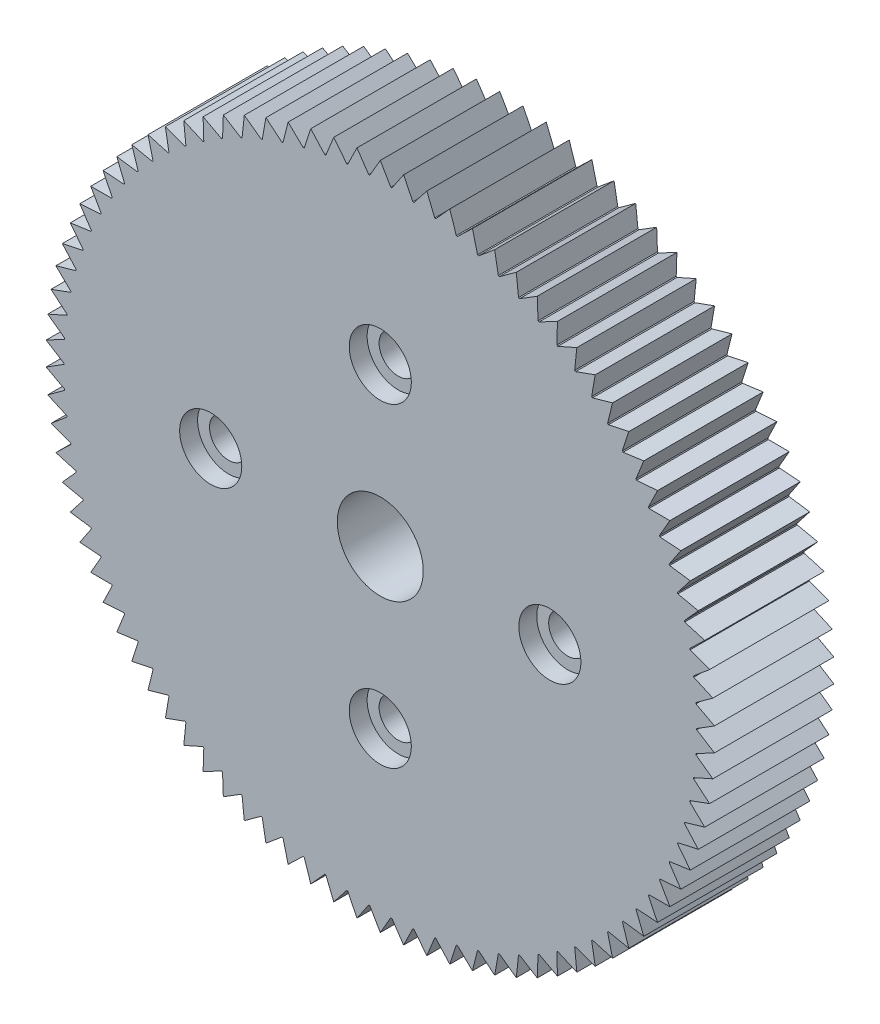
from build123d import *

# Parameters (mm, degrees)
SKETCH1_R      = 13.25
EXTRUDE1_DEPTH = 5
EXTRUDE2_DEPTH = 1.2
SKETCH3_R      = 1.8
EXTRUDE3_DEPTH = 4.8
SKETCH4_R      = 0.8
EXTRUDE4_DEPTH = 4.8
SKETCH5_R      = 1.3
EXTRUDE5_DEPTH = 0.75
EXTRUDE6_DEPTH = 5


with BuildPart() as part:
    # Sketch1 → Extrude1 (new body)
    with BuildSketch(Plane.XY):
        Circle(SKETCH1_R)
    extrude(amount=EXTRUDE1_DEPTH)

    # Sketch2 → Extrude2 (cut)
    with BuildSketch(Plane(origin=(0, 0, 0), x_dir=(-1, 0, 0), z_dir=(0, 0, -1))):
        with BuildLine():
            Line((-7.1, 1.675), (-2.36735612, 1.675))
            ThreePointArc((-2.36735612, 1.675), (-2.050609665, 2.050609665), (-1.675, 2.36735612))
            Line((-1.675, 2.36735612), (-1.675, 6.6))
            ThreePointArc((-1.675, 6.6), (0, 8.275), (1.675, 6.6))
            Line((1.675, 6.6), (1.675, 2.36735612))
            ThreePointArc((1.675, 2.36735612), (2.050609665, 2.050609665), (2.36735612, 1.675))
            Line((2.36735612, 1.675), (7.1, 1.675))
            ThreePointArc((7.1, 1.675), (8.775, 0), (7.1, -1.675))
            Line((7.1, -1.675), (2.36735612, -1.675))
            ThreePointArc((2.36735612, -1.675), (2.050609665, -2.050609665), (1.675, -2.36735612))
            Line((1.675, -2.36735612), (1.675, -6.6))
            ThreePointArc((1.675, -6.6), (0, -8.275), (-1.675, -6.6))
            Line((-1.675, -6.6), (-1.675, -2.36735612))
            ThreePointArc((-1.675, -2.36735612), (-2.050609665, -2.050609665), (-2.36735612, -1.675))
            Line((-2.36735612, -1.675), (-7.1, -1.675))
            ThreePointArc((-7.1, -1.675), (-8.775, 0), (-7.1, 1.675))
        make_face()
    extrude(amount=-EXTRUDE2_DEPTH, mode=Mode.SUBTRACT)

    # Sketch3 → Extrude3 (cut, through all)
    with BuildSketch(Plane(origin=(0, 0, 1.2), x_dir=(-1, 0, 0), z_dir=(0, 0, -1))):
        Circle(SKETCH3_R)
    extrude(amount=-EXTRUDE3_DEPTH, mode=Mode.SUBTRACT)

    # Sketch4 → Extrude4 (cut, through all)
    with BuildSketch(Plane(origin=(0, 0, 1.2), x_dir=(-1, 0, 0), z_dir=(0, 0, -1))):
        with Locations((0, 6.6)):
            Circle(SKETCH4_R)
        with Locations((-7.1, 0)):
            Circle(SKETCH4_R)
        with Locations((0, -6.6)):
            Circle(SKETCH4_R)
        with Locations((7.1, 0)):
            Circle(SKETCH4_R)
    extrude(amount=-EXTRUDE4_DEPTH, mode=Mode.SUBTRACT)

    # Sketch5 → Extrude5 (cut)
    with BuildSketch(Plane.XY.offset(5)):
        with Locations((-7.1, 0)):
            Circle(SKETCH5_R)
        with Locations((0, -6.6)):
            Circle(SKETCH5_R)
        with Locations((7.1, 0)):
            Circle(SKETCH5_R)
        with Locations((0, 6.6)):
            Circle(SKETCH5_R)
    extrude(amount=-EXTRUDE5_DEPTH, mode=Mode.SUBTRACT)

    # Sketch6 → Extrude6 (add)
    with BuildSketch(Plane(origin=(0, 0, 0), x_dir=(-1, 0, 0), z_dir=(0, 0, -1))):
        with BuildLine():
            Line((0, 14), (-0.439306114, 13.242715361))
            ThreePointArc((-0.439306114, 13.242715361), (0, 13.25), (0.439306114, 13.242715361))
            Line((0.439306114, 13.242715361), (0, 14))
        make_face()
        with BuildLine():
            Line((1.362001112, 13.179812327), (0.976590632, 13.965896704))
            Line((0.976590632, 13.965896704), (0.48552914, 13.241101218))
            ThreePointArc((0.48552914, 13.241101218), (0.924273277, 13.217723666), (1.362001112, 13.179812327))
        make_face()
        with BuildLine():
            Line((2.278060579, 13.052698572), (1.948423413, 13.863752962))
            Line((1.948423413, 13.863752962), (1.407998945, 13.17497776))
            ThreePointArc((1.407998945, 13.17497776), (1.844043588, 13.121051911), (2.278060579, 13.052698572))
        make_face()
        with BuildLine():
            Line((3.183021563, 12.861993381), (2.910763671, 13.69406641))
            Line((2.910763671, 13.69406641), (2.323609121, 13.044667135))
            ThreePointArc((2.323609121, 13.044667135), (2.754829903, 12.96045571), (3.183021563, 12.861993381))
        make_face()
        with BuildLine():
            Line((4.072475186, 12.608625851), (3.858922981, 13.457663743))
            Line((3.858922981, 13.457663743), (3.227898906, 12.850804203))
            ThreePointArc((3.227898906, 12.850804203), (3.652194965, 12.736717471), (4.072475186, 12.608625851))
        make_face()
        with BuildLine():
            Line((4.942088119, 12.293830364), (4.788282007, 13.155696691))
            Line((4.788282007, 13.155696691), (4.116462693, 12.594333444))
            ThreePointArc((4.116462693, 12.594333444), (4.531766899, 12.450927225), (4.942088119, 12.293830364))
        make_face()
        with BuildLine():
            Line((5.787623696, 11.919140571), (5.694313003, 12.789636407))
            Line((5.694313003, 12.789636407), (4.984971487, 12.276504359))
            ThreePointArc((4.984971487, 12.276504359), (5.389260521, 12.104477314), (5.787623696, 11.919140571))
        make_face()
        with BuildLine():
            Line((6.604962552, 11.486381923), (6.572601879, 12.3612663))
            Line((6.572601879, 12.3612663), (5.829194001, 11.898865379))
            ThreePointArc((5.829194001, 11.898865379), (6.220498207, 11.699055605), (6.604962552, 11.486381923))
        make_face()
        with BuildLine():
            Line((7.390122694, 10.997662778), (7.418869699, 11.872673346))
            Line((7.418869699, 11.872673346), (6.645017267, 11.463256323))
            ThreePointArc((6.645017267, 11.463256323), (7.021430251, 11.236637274), (7.390122694, 10.997662778))
        make_face()
        with BuildLine():
            Line((8.139278901, 10.455364124), (8.228993532, 11.326237921))
            Line((8.228993532, 11.326237921), (7.428466678, 10.971799434))
            ThreePointArc((7.428466678, 10.971799434), (7.788154593, 10.719475175), (8.139278901, 10.455364124))
        make_face()
        with BuildLine():
            Line((8.84878136, 9.862127988), (8.999026536, 10.724622204))
            Line((8.999026536, 10.724622204), (8.175725346, 10.426889041))
            ThreePointArc((8.175725346, 10.426889041), (8.516935828, 10.150088871), (8.84878136, 9.862127988))
        make_face()
        with BuildLine():
            Line((9.515173445, 9.220844555), (9.725217186, 10.070757205))
            Line((9.725217186, 10.070757205), (8.883152701, 9.831179893))
            ThreePointArc((8.883152701, 9.831179893), (9.204223409, 9.531252354), (9.515173445, 9.220844555))
        make_face()
        with BuildLine():
            Line((10.135208562, 8.534638094), (10.404027557, 9.367828489))
            Line((10.404027557, 9.367828489), (9.54730223, 9.187574225))
            ThreePointArc((9.54730223, 9.187574225), (9.846668938, 8.865980534), (10.135208562, 8.534638094))
        make_face()
        with BuildLine():
            Line((10.705865962, 7.806851735), (11.03215055, 8.619260655))
            Line((11.03215055, 8.619260655), (10.164938262, 8.499207618))
            ThreePointArc((10.164938262, 8.499207618), (10.441142485, 8.157514548), (10.705865962, 7.806851735))
        make_face()
        with BuildLine():
            Line((11.224365458, 7.041031179), (11.606526016, 7.828700649))
            Line((11.606526016, 7.828700649), (10.733051736, 7.769433727))
            ThreePointArc((10.733051736, 7.769433727), (10.984747836, 7.409305971), (11.224365458, 7.041031179))
        make_face()
        with BuildLine():
            Line((11.688180975, 6.240907426), (12.124355653, 7))
            Line((12.124355653, 7), (11.248874861, 7.001807935))
            ThreePointArc((11.248874861, 7.001807935), (11.4748366, 6.625), (11.688180975, 6.240907426))
        make_face()
        with BuildLine():
            Line((12.095052848, 5.4103786), (12.583116648, 6.137196055))
            Line((12.583116648, 6.137196055), (11.709894599, 6.200070039))
            ThreePointArc((11.709894599, 6.200070039), (11.909021113, 5.808417695), (12.095052848, 5.4103786))
        make_face()
        with BuildLine():
            Line((12.44299884, 4.553490953), (12.980573964, 5.244492308))
            Line((12.980573964, 5.244492308), (12.113864907, 5.368126025))
            ThreePointArc((12.113864907, 5.368126025), (12.285186073, 4.963537363), (12.44299884, 4.553490953))
        make_face()
        with BuildLine():
            Line((12.730323793, 3.674419156), (13.314791228, 4.326237921))
            Line((13.314791228, 4.326237921), (12.458817683, 4.51002904))
            ThreePointArc((12.458817683, 4.51002904), (12.601498841, 4.094475175), (12.730323793, 3.674419156))
        make_face()
        with BuildLine():
            Line((12.955627887, 2.777445958), (13.584140168, 3.386906538))
            Line((13.584140168, 3.386906538), (12.743072352, 3.629959648))
            ThreePointArc((12.743072352, 3.629959648), (12.856418373, 3.205465117), (12.955627887, 2.777445958))
        make_face()
        with BuildLine():
            Line((13.117813465, 1.866941323), (13.787308542, 2.431074487))
            Line((13.787308542, 2.431074487), (12.965244053, 2.732205457))
            ThreePointArc((12.965244053, 2.732205457), (13.048702727, 2.300838354), (13.117813465, 1.866941323))
        make_face()
        with BuildLine():
            Line((13.216090374, 0.947341137), (13.923306535, 1.463398486))
            Line((13.923306535, 1.463398486), (13.124250388, 1.821140235))
            ThreePointArc((13.124250388, 1.821140235), (13.177415114, 1.385002138), (13.216090374, 0.947341137))
        make_face()
        with BuildLine():
            Line((13.249979819, 0.023125601), (13.991471578, 0.488592954))
            Line((13.991471578, 0.488592954), (13.219316695, 0.901202601))
            ThreePointArc((13.219316695, 0.901202601), (13.241928458, 0.462418331), (13.249979819, 0.023125601))
        make_face()
        with BuildLine():
            Line((13.219316695, -0.901202601), (13.991471578, -0.488592954))
            Line((13.991471578, -0.488592954), (13.249979819, -0.023125601))
            ThreePointArc((13.249979819, -0.023125601), (13.241928458, -0.462418331), (13.219316695, -0.901202601))
        make_face()
        with BuildLine():
            Line((13.124250388, -1.821140235), (13.923306535, -1.463398486))
            Line((13.923306535, -1.463398486), (13.216090374, -0.947341137))
            ThreePointArc((13.216090374, -0.947341137), (13.177415114, -1.385002138), (13.124250388, -1.821140235))
        make_face()
        with BuildLine():
            Line((12.965244053, -2.732205457), (13.787308542, -2.431074487))
            Line((13.787308542, -2.431074487), (13.117813465, -1.866941323))
            ThreePointArc((13.117813465, -1.866941323), (13.048702727, -2.300838354), (12.965244053, -2.732205457))
        make_face()
        with BuildLine():
            Line((12.743072352, -3.629959648), (13.584140168, -3.386906538))
            Line((13.584140168, -3.386906538), (12.955627887, -2.777445958))
            ThreePointArc((12.955627887, -2.777445958), (12.856418373, -3.205465117), (12.743072352, -3.629959648))
        make_face()
        with BuildLine():
            Line((12.458817683, -4.51002904), (13.314791228, -4.326237921))
            Line((13.314791228, -4.326237921), (12.730323793, -3.674419156))
            ThreePointArc((12.730323793, -3.674419156), (12.601498841, -4.094475175), (12.458817683, -4.51002904))
        make_face()
        with BuildLine():
            Line((12.113864907, -5.368126025), (12.980573964, -5.244492308))
            Line((12.980573964, -5.244492308), (12.44299884, -4.553490953))
            ThreePointArc((12.44299884, -4.553490953), (12.285186073, -4.963537363), (12.113864907, -5.368126025))
        make_face()
        with BuildLine():
            Line((11.709894599, -6.200070039), (12.583116648, -6.137196055))
            Line((12.583116648, -6.137196055), (12.095052848, -5.4103786))
            ThreePointArc((12.095052848, -5.4103786), (11.909021113, -5.808417695), (11.709894599, -6.200070039))
        make_face()
        with BuildLine():
            Line((11.248874861, -7.001807935), (12.124355653, -7))
            Line((12.124355653, -7), (11.688180975, -6.240907426))
            ThreePointArc((11.688180975, -6.240907426), (11.4748366, -6.625), (11.248874861, -7.001807935))
        make_face()
        with BuildLine():
            Line((10.733051736, -7.769433727), (11.606526016, -7.828700649))
            Line((11.606526016, -7.828700649), (11.224365458, -7.041031179))
            ThreePointArc((11.224365458, -7.041031179), (10.984747836, -7.409305971), (10.733051736, -7.769433727))
        make_face()
        with BuildLine():
            Line((10.164938262, -8.499207618), (11.03215055, -8.619260655))
            Line((11.03215055, -8.619260655), (10.705865962, -7.806851735))
            ThreePointArc((10.705865962, -7.806851735), (10.441142485, -8.157514548), (10.164938262, -8.499207618))
        make_face()
        with BuildLine():
            Line((9.54730223, -9.187574225), (10.404027557, -9.367828489))
            Line((10.404027557, -9.367828489), (10.135208562, -8.534638094))
            ThreePointArc((10.135208562, -8.534638094), (9.846668938, -8.865980534), (9.54730223, -9.187574225))
        make_face()
        with BuildLine():
            Line((8.883152701, -9.831179893), (9.725217186, -10.070757205))
            Line((9.725217186, -10.070757205), (9.515173445, -9.220844555))
            ThreePointArc((9.515173445, -9.220844555), (9.204223409, -9.531252354), (8.883152701, -9.831179893))
        make_face()
        with BuildLine():
            Line((8.175725346, -10.426889041), (8.999026536, -10.724622204))
            Line((8.999026536, -10.724622204), (8.84878136, -9.862127988))
            ThreePointArc((8.84878136, -9.862127988), (8.516935828, -10.150088871), (8.175725346, -10.426889041))
        make_face()
        with BuildLine():
            Line((7.428466678, -10.971799434), (8.228993532, -11.326237921))
            Line((8.228993532, -11.326237921), (8.139278901, -10.455364124))
            ThreePointArc((8.139278901, -10.455364124), (7.788154593, -10.719475175), (7.428466678, -10.971799434))
        make_face()
        with BuildLine():
            Line((6.645017267, -11.463256323), (7.418869699, -11.872673346))
            Line((7.418869699, -11.872673346), (7.390122694, -10.997662778))
            ThreePointArc((7.390122694, -10.997662778), (7.021430251, -11.236637274), (6.645017267, -11.463256323))
        make_face()
        with BuildLine():
            Line((5.829194001, -11.898865379), (6.572601879, -12.3612663))
            Line((6.572601879, -12.3612663), (6.604962552, -11.486381923))
            ThreePointArc((6.604962552, -11.486381923), (6.220498207, -11.699055605), (5.829194001, -11.898865379))
        make_face()
        with BuildLine():
            Line((4.984971487, -12.276504359), (5.694313003, -12.789636407))
            Line((5.694313003, -12.789636407), (5.787623696, -11.919140571))
            ThreePointArc((5.787623696, -11.919140571), (5.389260521, -12.104477314), (4.984971487, -12.276504359))
        make_face()
        with BuildLine():
            Line((4.116462693, -12.594333444), (4.788282007, -13.155696691))
            Line((4.788282007, -13.155696691), (4.942088119, -12.293830364))
            ThreePointArc((4.942088119, -12.293830364), (4.531766899, -12.450927225), (4.116462693, -12.594333444))
        make_face()
        with BuildLine():
            Line((3.227898906, -12.850804203), (3.858922981, -13.457663743))
            Line((3.858922981, -13.457663743), (4.072475186, -12.608625851))
            ThreePointArc((4.072475186, -12.608625851), (3.652194965, -12.736717471), (3.227898906, -12.850804203))
        make_face()
        with BuildLine():
            Line((2.323609121, -13.044667135), (2.910763671, -13.69406641))
            Line((2.910763671, -13.69406641), (3.183021563, -12.861993381))
            ThreePointArc((3.183021563, -12.861993381), (2.754829903, -12.96045571), (2.323609121, -13.044667135))
        make_face()
        with BuildLine():
            Line((1.407998945, -13.17497776), (1.948423413, -13.863752962))
            Line((1.948423413, -13.863752962), (2.278060579, -13.052698572))
            ThreePointArc((2.278060579, -13.052698572), (1.844043588, -13.121051911), (1.407998945, -13.17497776))
        make_face()
        with BuildLine():
            Line((0.48552914, -13.241101218), (0.976590632, -13.965896704))
            Line((0.976590632, -13.965896704), (1.362001112, -13.179812327))
            ThreePointArc((1.362001112, -13.179812327), (0.924273277, -13.217723666), (0.48552914, -13.241101218))
        make_face()
        with BuildLine():
            Line((-0.439306114, -13.242715361), (0, -14))
            Line((0, -14), (0.439306114, -13.242715361))
            ThreePointArc((0.439306114, -13.242715361), (0, -13.25), (-0.439306114, -13.242715361))
        make_face()
        with BuildLine():
            Line((-1.362001112, -13.179812327), (-0.976590632, -13.965896704))
            Line((-0.976590632, -13.965896704), (-0.48552914, -13.241101218))
            ThreePointArc((-0.48552914, -13.241101218), (-0.924273277, -13.217723666), (-1.362001112, -13.179812327))
        make_face()
        with BuildLine():
            Line((-2.278060579, -13.052698572), (-1.948423413, -13.863752962))
            Line((-1.948423413, -13.863752962), (-1.407998945, -13.17497776))
            ThreePointArc((-1.407998945, -13.17497776), (-1.844043588, -13.121051911), (-2.278060579, -13.052698572))
        make_face()
        with BuildLine():
            Line((-3.183021563, -12.861993381), (-2.910763671, -13.69406641))
            Line((-2.910763671, -13.69406641), (-2.323609121, -13.044667135))
            ThreePointArc((-2.323609121, -13.044667135), (-2.754829903, -12.96045571), (-3.183021563, -12.861993381))
        make_face()
        with BuildLine():
            Line((-4.072475186, -12.608625851), (-3.858922981, -13.457663743))
            Line((-3.858922981, -13.457663743), (-3.227898906, -12.850804203))
            ThreePointArc((-3.227898906, -12.850804203), (-3.652194965, -12.736717471), (-4.072475186, -12.608625851))
        make_face()
        with BuildLine():
            Line((-4.942088119, -12.293830364), (-4.788282007, -13.155696691))
            Line((-4.788282007, -13.155696691), (-4.116462693, -12.594333444))
            ThreePointArc((-4.116462693, -12.594333444), (-4.531766899, -12.450927225), (-4.942088119, -12.293830364))
        make_face()
        with BuildLine():
            Line((-5.787623696, -11.919140571), (-5.694313003, -12.789636407))
            Line((-5.694313003, -12.789636407), (-4.984971487, -12.276504359))
            ThreePointArc((-4.984971487, -12.276504359), (-5.389260521, -12.104477314), (-5.787623696, -11.919140571))
        make_face()
        with BuildLine():
            Line((-6.604962552, -11.486381923), (-6.572601879, -12.3612663))
            Line((-6.572601879, -12.3612663), (-5.829194001, -11.898865379))
            ThreePointArc((-5.829194001, -11.898865379), (-6.220498207, -11.699055605), (-6.604962552, -11.486381923))
        make_face()
        with BuildLine():
            Line((-7.390122694, -10.997662778), (-7.418869699, -11.872673346))
            Line((-7.418869699, -11.872673346), (-6.645017267, -11.463256323))
            ThreePointArc((-6.645017267, -11.463256323), (-7.021430251, -11.236637274), (-7.390122694, -10.997662778))
        make_face()
        with BuildLine():
            Line((-8.139278901, -10.455364124), (-8.228993532, -11.326237921))
            Line((-8.228993532, -11.326237921), (-7.428466678, -10.971799434))
            ThreePointArc((-7.428466678, -10.971799434), (-7.788154593, -10.719475175), (-8.139278901, -10.455364124))
        make_face()
        with BuildLine():
            Line((-8.84878136, -9.862127988), (-8.999026536, -10.724622204))
            Line((-8.999026536, -10.724622204), (-8.175725346, -10.426889041))
            ThreePointArc((-8.175725346, -10.426889041), (-8.516935828, -10.150088871), (-8.84878136, -9.862127988))
        make_face()
        with BuildLine():
            Line((-9.515173445, -9.220844555), (-9.725217186, -10.070757205))
            Line((-9.725217186, -10.070757205), (-8.883152701, -9.831179893))
            ThreePointArc((-8.883152701, -9.831179893), (-9.204223409, -9.531252354), (-9.515173445, -9.220844555))
        make_face()
        with BuildLine():
            Line((-10.135208562, -8.534638094), (-10.404027557, -9.367828489))
            Line((-10.404027557, -9.367828489), (-9.54730223, -9.187574225))
            ThreePointArc((-9.54730223, -9.187574225), (-9.846668938, -8.865980534), (-10.135208562, -8.534638094))
        make_face()
        with BuildLine():
            Line((-10.705865962, -7.806851735), (-11.03215055, -8.619260655))
            Line((-11.03215055, -8.619260655), (-10.164938262, -8.499207618))
            ThreePointArc((-10.164938262, -8.499207618), (-10.441142485, -8.157514548), (-10.705865962, -7.806851735))
        make_face()
        with BuildLine():
            Line((-11.224365458, -7.041031179), (-11.606526016, -7.828700649))
            Line((-11.606526016, -7.828700649), (-10.733051736, -7.769433727))
            ThreePointArc((-10.733051736, -7.769433727), (-10.984747836, -7.409305971), (-11.224365458, -7.041031179))
        make_face()
        with BuildLine():
            Line((-11.688180975, -6.240907426), (-12.124355653, -7))
            Line((-12.124355653, -7), (-11.248874861, -7.001807935))
            ThreePointArc((-11.248874861, -7.001807935), (-11.4748366, -6.625), (-11.688180975, -6.240907426))
        make_face()
        with BuildLine():
            Line((-12.095052848, -5.4103786), (-12.583116648, -6.137196055))
            Line((-12.583116648, -6.137196055), (-11.709894599, -6.200070039))
            ThreePointArc((-11.709894599, -6.200070039), (-11.909021113, -5.808417695), (-12.095052848, -5.4103786))
        make_face()
        with BuildLine():
            Line((-12.44299884, -4.553490953), (-12.980573964, -5.244492308))
            Line((-12.980573964, -5.244492308), (-12.113864907, -5.368126025))
            ThreePointArc((-12.113864907, -5.368126025), (-12.285186073, -4.963537363), (-12.44299884, -4.553490953))
        make_face()
        with BuildLine():
            Line((-12.730323793, -3.674419156), (-13.314791228, -4.326237921))
            Line((-13.314791228, -4.326237921), (-12.458817683, -4.51002904))
            ThreePointArc((-12.458817683, -4.51002904), (-12.601498841, -4.094475175), (-12.730323793, -3.674419156))
        make_face()
        with BuildLine():
            Line((-12.955627887, -2.777445958), (-13.584140168, -3.386906538))
            Line((-13.584140168, -3.386906538), (-12.743072352, -3.629959648))
            ThreePointArc((-12.743072352, -3.629959648), (-12.856418373, -3.205465117), (-12.955627887, -2.777445958))
        make_face()
        with BuildLine():
            Line((-13.117813465, -1.866941323), (-13.787308542, -2.431074487))
            Line((-13.787308542, -2.431074487), (-12.965244053, -2.732205457))
            ThreePointArc((-12.965244053, -2.732205457), (-13.048702727, -2.300838354), (-13.117813465, -1.866941323))
        make_face()
        with BuildLine():
            Line((-13.216090374, -0.947341137), (-13.923306535, -1.463398486))
            Line((-13.923306535, -1.463398486), (-13.124250388, -1.821140235))
            ThreePointArc((-13.124250388, -1.821140235), (-13.177415114, -1.385002138), (-13.216090374, -0.947341137))
        make_face()
        with BuildLine():
            Line((-13.249979819, -0.023125601), (-13.991471578, -0.488592954))
            Line((-13.991471578, -0.488592954), (-13.219316695, -0.901202601))
            ThreePointArc((-13.219316695, -0.901202601), (-13.241928458, -0.462418331), (-13.249979819, -0.023125601))
        make_face()
        with BuildLine():
            Line((-13.219316695, 0.901202601), (-13.991471578, 0.488592954))
            Line((-13.991471578, 0.488592954), (-13.249979819, 0.023125601))
            ThreePointArc((-13.249979819, 0.023125601), (-13.241928458, 0.462418331), (-13.219316695, 0.901202601))
        make_face()
        with BuildLine():
            Line((-13.124250388, 1.821140235), (-13.923306535, 1.463398486))
            Line((-13.923306535, 1.463398486), (-13.216090374, 0.947341137))
            ThreePointArc((-13.216090374, 0.947341137), (-13.177415114, 1.385002138), (-13.124250388, 1.821140235))
        make_face()
        with BuildLine():
            Line((-12.965244053, 2.732205457), (-13.787308542, 2.431074487))
            Line((-13.787308542, 2.431074487), (-13.117813465, 1.866941323))
            ThreePointArc((-13.117813465, 1.866941323), (-13.048702727, 2.300838354), (-12.965244053, 2.732205457))
        make_face()
        with BuildLine():
            Line((-12.743072352, 3.629959648), (-13.584140168, 3.386906538))
            Line((-13.584140168, 3.386906538), (-12.955627887, 2.777445958))
            ThreePointArc((-12.955627887, 2.777445958), (-12.856418373, 3.205465117), (-12.743072352, 3.629959648))
        make_face()
        with BuildLine():
            Line((-12.458817683, 4.51002904), (-13.314791228, 4.326237921))
            Line((-13.314791228, 4.326237921), (-12.730323793, 3.674419156))
            ThreePointArc((-12.730323793, 3.674419156), (-12.601498841, 4.094475175), (-12.458817683, 4.51002904))
        make_face()
        with BuildLine():
            Line((-12.113864907, 5.368126025), (-12.980573964, 5.244492308))
            Line((-12.980573964, 5.244492308), (-12.44299884, 4.553490953))
            ThreePointArc((-12.44299884, 4.553490953), (-12.285186073, 4.963537363), (-12.113864907, 5.368126025))
        make_face()
        with BuildLine():
            Line((-11.709894599, 6.200070039), (-12.583116648, 6.137196055))
            Line((-12.583116648, 6.137196055), (-12.095052848, 5.4103786))
            ThreePointArc((-12.095052848, 5.4103786), (-11.909021113, 5.808417695), (-11.709894599, 6.200070039))
        make_face()
        with BuildLine():
            Line((-11.248874861, 7.001807935), (-12.124355653, 7))
            Line((-12.124355653, 7), (-11.688180975, 6.240907426))
            ThreePointArc((-11.688180975, 6.240907426), (-11.4748366, 6.625), (-11.248874861, 7.001807935))
        make_face()
        with BuildLine():
            Line((-10.733051736, 7.769433727), (-11.606526016, 7.828700649))
            Line((-11.606526016, 7.828700649), (-11.224365458, 7.041031179))
            ThreePointArc((-11.224365458, 7.041031179), (-10.984747836, 7.409305971), (-10.733051736, 7.769433727))
        make_face()
        with BuildLine():
            Line((-10.164938262, 8.499207618), (-11.03215055, 8.619260655))
            Line((-11.03215055, 8.619260655), (-10.705865962, 7.806851735))
            ThreePointArc((-10.705865962, 7.806851735), (-10.441142485, 8.157514548), (-10.164938262, 8.499207618))
        make_face()
        with BuildLine():
            Line((-9.54730223, 9.187574225), (-10.404027557, 9.367828489))
            Line((-10.404027557, 9.367828489), (-10.135208562, 8.534638094))
            ThreePointArc((-10.135208562, 8.534638094), (-9.846668938, 8.865980534), (-9.54730223, 9.187574225))
        make_face()
        with BuildLine():
            Line((-8.883152701, 9.831179893), (-9.725217186, 10.070757205))
            Line((-9.725217186, 10.070757205), (-9.515173445, 9.220844555))
            ThreePointArc((-9.515173445, 9.220844555), (-9.204223409, 9.531252354), (-8.883152701, 9.831179893))
        make_face()
        with BuildLine():
            Line((-8.175725346, 10.426889041), (-8.999026536, 10.724622204))
            Line((-8.999026536, 10.724622204), (-8.84878136, 9.862127988))
            ThreePointArc((-8.84878136, 9.862127988), (-8.516935828, 10.150088871), (-8.175725346, 10.426889041))
        make_face()
        with BuildLine():
            Line((-7.428466678, 10.971799434), (-8.228993532, 11.326237921))
            Line((-8.228993532, 11.326237921), (-8.139278901, 10.455364124))
            ThreePointArc((-8.139278901, 10.455364124), (-7.788154593, 10.719475175), (-7.428466678, 10.971799434))
        make_face()
        with BuildLine():
            Line((-6.645017267, 11.463256323), (-7.418869699, 11.872673346))
            Line((-7.418869699, 11.872673346), (-7.390122694, 10.997662778))
            ThreePointArc((-7.390122694, 10.997662778), (-7.021430251, 11.236637274), (-6.645017267, 11.463256323))
        make_face()
        with BuildLine():
            Line((-5.829194001, 11.898865379), (-6.572601879, 12.3612663))
            Line((-6.572601879, 12.3612663), (-6.604962552, 11.486381923))
            ThreePointArc((-6.604962552, 11.486381923), (-6.220498207, 11.699055605), (-5.829194001, 11.898865379))
        make_face()
        with BuildLine():
            Line((-4.984971487, 12.276504359), (-5.694313003, 12.789636407))
            Line((-5.694313003, 12.789636407), (-5.787623696, 11.919140571))
            ThreePointArc((-5.787623696, 11.919140571), (-5.389260521, 12.104477314), (-4.984971487, 12.276504359))
        make_face()
        with BuildLine():
            Line((-4.116462693, 12.594333444), (-4.788282007, 13.155696691))
            Line((-4.788282007, 13.155696691), (-4.942088119, 12.293830364))
            ThreePointArc((-4.942088119, 12.293830364), (-4.531766899, 12.450927225), (-4.116462693, 12.594333444))
        make_face()
        with BuildLine():
            Line((-3.227898906, 12.850804203), (-3.858922981, 13.457663743))
            Line((-3.858922981, 13.457663743), (-4.072475186, 12.608625851))
            ThreePointArc((-4.072475186, 12.608625851), (-3.652194965, 12.736717471), (-3.227898906, 12.850804203))
        make_face()
        with BuildLine():
            Line((-2.323609121, 13.044667135), (-2.910763671, 13.69406641))
            Line((-2.910763671, 13.69406641), (-3.183021563, 12.861993381))
            ThreePointArc((-3.183021563, 12.861993381), (-2.754829903, 12.96045571), (-2.323609121, 13.044667135))
        make_face()
        with BuildLine():
            Line((-1.407998945, 13.17497776), (-1.948423413, 13.863752962))
            Line((-1.948423413, 13.863752962), (-2.278060579, 13.052698572))
            ThreePointArc((-2.278060579, 13.052698572), (-1.844043588, 13.121051911), (-1.407998945, 13.17497776))
        make_face()
        with BuildLine():
            Line((-0.48552914, 13.241101218), (-0.976590632, 13.965896704))
            Line((-0.976590632, 13.965896704), (-1.362001112, 13.179812327))
            ThreePointArc((-1.362001112, 13.179812327), (-0.924273277, 13.217723666), (-0.48552914, 13.241101218))
        make_face()
    extrude(amount=-EXTRUDE6_DEPTH)


solid = part.part
